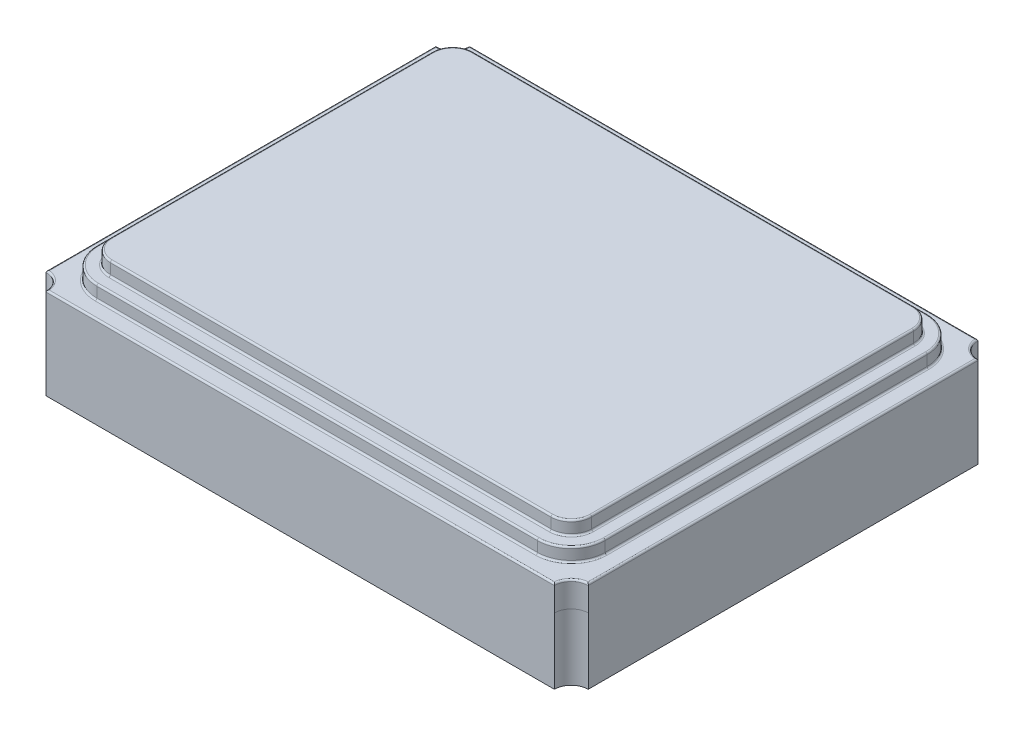
from build123d import *

# Parameters (mm, degrees)
BOSS_EXTRUDE1_DEPTH = 0.54
BOSS_EXTRUDE2_DEPTH = 0.08
BOSS_EXTRUDE3_DEPTH = 0.08
FILLET1_R           = 0.01


with BuildPart() as part:
    # Sketch1 → Boss-Extrude1 (new body)
    with BuildSketch(Plane(origin=(0, 0, 0), x_dir=(1, 0, 0), z_dir=(0, 1, 0))):
        with BuildLine():
            Line((-1.5, 1.25), (1.5, 1.25))
            ThreePointArc((1.5, 1.25), (1.529289322, 1.179289322), (1.6, 1.15))
            Line((1.6, 1.15), (1.6, -1.15))
            ThreePointArc((1.6, -1.15), (1.529289322, -1.179289322), (1.5, -1.25))
            Line((1.5, -1.25), (-1.5, -1.25))
            ThreePointArc((-1.5, -1.25), (-1.529289322, -1.179289322), (-1.6, -1.15))
            Line((-1.6, -1.15), (-1.6, 1.15))
            ThreePointArc((-1.6, 1.15), (-1.529289322, 1.179289322), (-1.5, 1.25))
        make_face()
    extrude(amount=BOSS_EXTRUDE1_DEPTH)

    # Sketch2 → Boss-Extrude2 (add)
    with BuildSketch(Plane(origin=(0, 0.54, 0), x_dir=(1, 0, 0), z_dir=(0, 1, 0))):
        with BuildLine():
            Line((-1.3, 1.15), (1.3, 1.15))
            ThreePointArc((1.3, 1.15), (1.441421356, 1.091421356), (1.5, 0.95))
            Line((1.5, 0.95), (1.5, -0.95))
            ThreePointArc((1.5, -0.95), (1.441421356, -1.091421356), (1.3, -1.15))
            Line((1.3, -1.15), (-1.3, -1.15))
            ThreePointArc((-1.3, -1.15), (-1.441421356, -1.091421356), (-1.5, -0.95))
            Line((-1.5, -0.95), (-1.5, 0.95))
            ThreePointArc((-1.5, 0.95), (-1.441421356, 1.091421356), (-1.3, 1.15))
        make_face()
    extrude(amount=BOSS_EXTRUDE2_DEPTH)

    # Sketch4 → Boss-Extrude3 (add)
    with BuildSketch(Plane(origin=(0, 0.62, 0), x_dir=(1, 0, 0), z_dir=(0, 1, 0))):
        with BuildLine():
            Line((1.42, -0.95), (1.42, 0.95))
            ThreePointArc((1.42, 0.95), (1.384852814, 1.034852814), (1.3, 1.07))
            Line((1.3, 1.07), (-1.3, 1.07))
            ThreePointArc((-1.3, 1.07), (-1.384852814, 1.034852814), (-1.42, 0.95))
            Line((-1.42, 0.95), (-1.42, -0.95))
            ThreePointArc((-1.42, -0.95), (-1.384852814, -1.034852814), (-1.3, -1.07))
            Line((-1.3, -1.07), (1.3, -1.07))
            ThreePointArc((1.3, -1.07), (1.384852814, -1.034852814), (1.42, -0.95))
        make_face()
    extrude(amount=BOSS_EXTRUDE3_DEPTH)

    # Fillet1
    fillet1_edges = [part.edges().sort_by_distance(p)[0] for p in [
        (1.529289322, 0.54, -1.179289322),
        (0, 0.54, -1.25),
        (-1.529289322, 0.54, -1.179289322),
        (-1.6, 0.54, 0),
        (-1.529289322, 0.54, 1.179289322),
        (0, 0.54, 1.25),
        (1.441421356, 0.54, 1.091421356),
        (1.5, 0.54, 0),
        (1.441421356, 0.54, -1.091421356),
        (0, 0.54, -1.15),
        (-1.441421356, 0.54, -1.091421356),
        (-1.5, 0.54, 0),
        (-1.441421356, 0.54, 1.091421356),
        (0, 0.54, 1.15),
        (1.441421356, 0.62, 1.091421356),
        (1.5, 0.62, 0),
        (1.441421356, 0.62, -1.091421356),
        (0, 0.62, -1.15),
        (-1.441421356, 0.62, -1.091421356),
        (-1.5, 0.62, 0),
        (-1.441421356, 0.62, 1.091421356),
        (0, 0.62, 1.15),
        (1.529289322, 0.54, 1.179289322),
        (1.384852814, 0.62, 1.034852814),
        (1.42, 0.62, 0),
        (1.384852814, 0.62, -1.034852814),
        (0, 0.62, -1.07),
        (-1.384852814, 0.62, -1.034852814),
        (-1.42, 0.62, 0),
        (-1.384852814, 0.62, 1.034852814),
        (0, 0.62, 1.07),
        (1.384852814, 0.7, 1.034852814),
        (1.42, 0.7, 0),
        (1.384852814, 0.7, -1.034852814),
        (0, 0.7, -1.07),
        (-1.384852814, 0.7, -1.034852814),
        (-1.42, 0.7, 0),
        (-1.384852814, 0.7, 1.034852814),
        (0, 0.7, 1.07),
        (1.6, 0.54, 0),
    ]]
    fillet(fillet1_edges, radius=FILLET1_R)


solid = part.part
